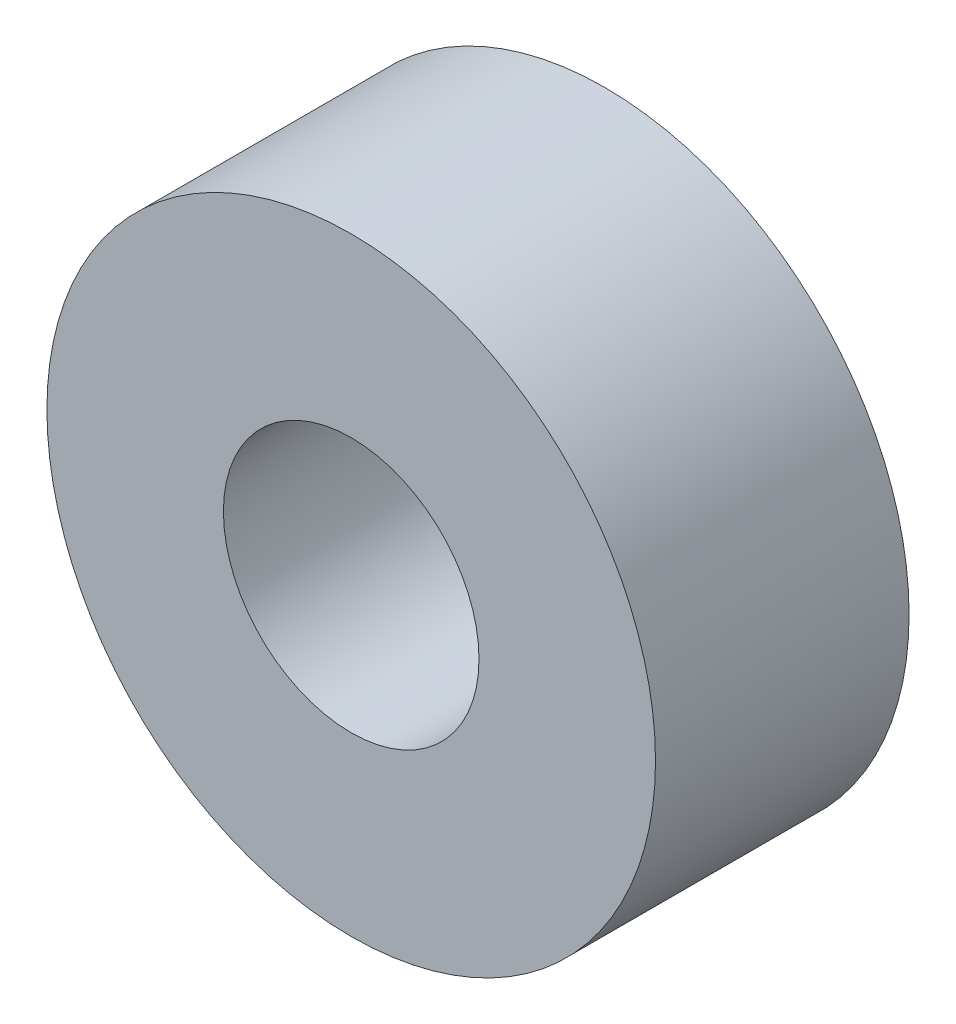
from build123d import *

# Parameters (mm, degrees)
SKETCH1_R      = 9.525
SKETCH1_R_2    = 4.0005
EXTRUDE1_DEPTH = 3.96875


with BuildPart() as part:
    # Sketch1 → Extrude1 (new body, symmetric)
    with BuildSketch(Plane.XY):
        Circle(SKETCH1_R)
        Circle(SKETCH1_R_2, mode=Mode.SUBTRACT)
    extrude(amount=EXTRUDE1_DEPTH, both=True)


solid = part.part
